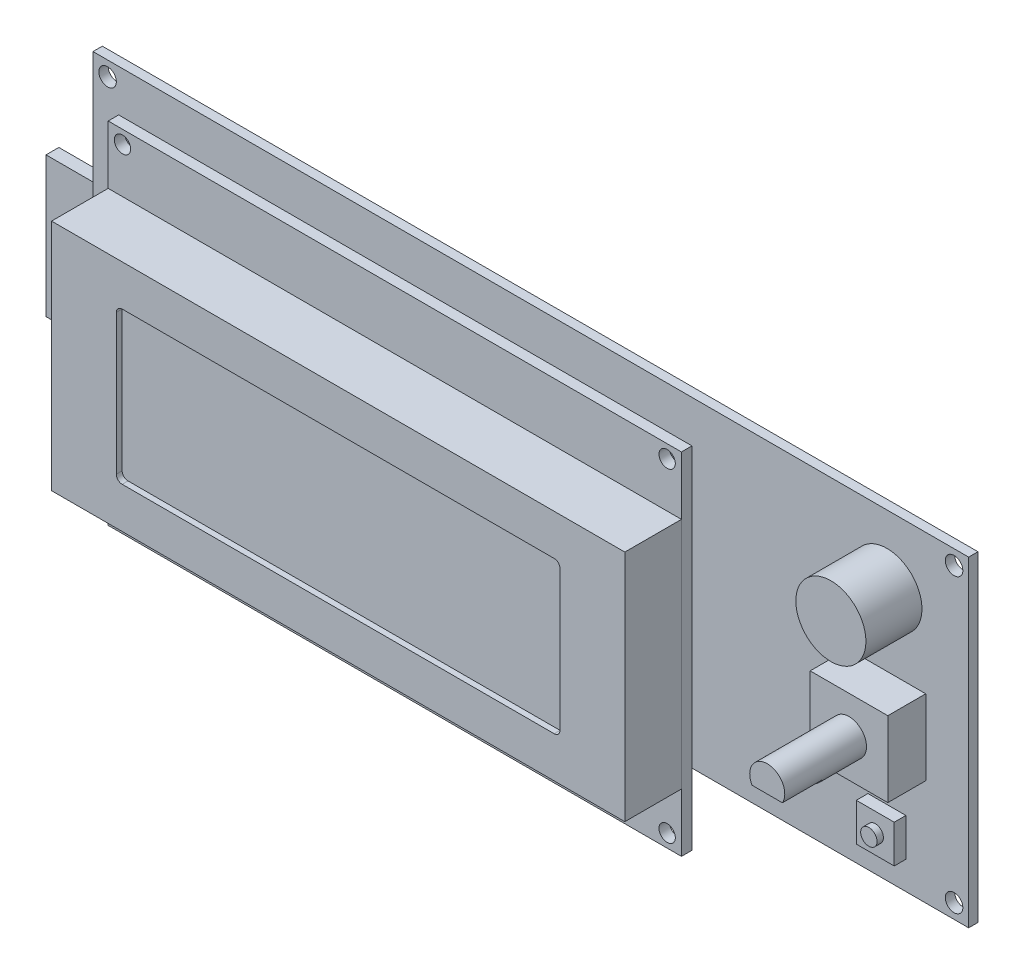
from build123d import *

# Parameters (mm, degrees)
SKETCH1_W                           = 150
SKETCH1_H                           = 55
PCB_DEPTH                           = 1.6
F_3_0_3_DIAMETER_HOLE1_D            = 3
F_3_0_3_DIAMETER_HOLE1_DEPTH        = 4
F_3_0_3_DIAMETER_HOLE1_TIP          = 0.901290929
SKETCH4_W                           = 20.3
SKETCH4_H                           = 8.8
IDC_CONN_DEPTH                      = 17.5
LPATTERN1_COUNT                     = 2
LPATTERN1_PITCH                     = 22.86
SKETCH5_W                           = 25.7
SKETCH5_H                           = 26.6
SD_SOCKET_DEPTH                     = 3.3
SKETCH6_W                           = 2.2
SKETCH6_H                           = 24
SD_CARD_DEPTH                       = 10.2
SKETCH7_R                           = 1.75
CONTRAST_POT_DEPTH                  = 2.5
EXTRUDE_2N3901_DEPTH                = 7
SKETCH9_W                           = 98.2
SKETCH9_H                           = 60
LCD_PCB_DEPTH                       = 1.8
SKETCH10_W                          = 98.2
SKETCH10_H                          = 40
LCD_HOUSING_DEPTH                   = 9.7
SKETCH11_W                          = 76
SKETCH11_H                          = 26
CUT_EXTRUDE1_DEPTH                  = 1
FILLET1_R                           = 1
F_2_8_2_8_DIAMETER_HOLE1_AT_2_COUNT = 2
F_2_8_2_8_DIAMETER_HOLE1_AT_2_PITCH = 93.3
F_2_8_2_8_DIAMETER_HOLE1_AT_3_COUNT = 2
F_2_8_2_8_DIAMETER_HOLE1_AT_3_PITCH = 108.55938467
F_2_8_2_8_DIAMETER_HOLE1_AT_4_COUNT = 2
F_2_8_2_8_DIAMETER_HOLE1_AT_4_PITCH = 55.5
SKETCH14_R                          = 6
BUZZER_DEPTH                        = 9.6
SKETCH15_W                          = 13.3
SKETCH15_H                          = 12.9
ENC_BODY_DEPTH                      = 6.5
SKETCH16_R                          = 3
ENC_SHAFT_DEPTH                     = 14
SKETCH17_W                          = 5.196152422
SKETCH17_H                          = 1.5
ENC_SHAFT_FLAT_DEPTH                = 6.8
SKETCH18_W                          = 6.5
SKETCH18_H                          = 6.5
E_STOP_SW_BODY_DEPTH                = 2
SKETCH19_R                          = 1.4
E_STOP_SW_BUTTON_DEPTH              = 1.1


with BuildPart() as part:
    # Sketch1 → PCB (new body)
    with BuildSketch(Plane.XY):
        Rectangle(SKETCH1_W, SKETCH1_H)
    extrude(amount=-PCB_DEPTH)

    # Ø3.0 (3) Diameter Hole1
    with Locations(Plane.XY):
        with Locations((-72.5, 25), (72.5, 25), (72.5, -25), (-72.5, -25)):
            Hole(F_3_0_3_DIAMETER_HOLE1_D / 2, depth=F_3_0_3_DIAMETER_HOLE1_DEPTH)
            with Locations((0, 0, -(F_3_0_3_DIAMETER_HOLE1_DEPTH + F_3_0_3_DIAMETER_HOLE1_TIP / 2))):  # 118° drill point
                Cone(0, F_3_0_3_DIAMETER_HOLE1_D / 2, F_3_0_3_DIAMETER_HOLE1_TIP, mode=Mode.SUBTRACT)

    # Sketch4 → IDC conn (add)
    with BuildSketch(Plane(origin=(0, 0, -1.6), x_dir=(-1, 0, 0), z_dir=(0, 0, -1))):
        with Locations((-4.05, 0.6)):
            Rectangle(SKETCH4_W, SKETCH4_H)
    idc_conn = extrude(amount=IDC_CONN_DEPTH)

    # LPattern1: IDC conn ×2
    with Locations(*[(-i * LPATTERN1_PITCH, 0, 0) for i in range(1, LPATTERN1_COUNT)]):
        add(idc_conn)



with BuildPart() as body_2:
    # Sketch5 → SD socket (new body)
    with BuildSketch(Plane(origin=(0, 0, -1.6), x_dir=(-1, 0, 0), z_dir=(0, 0, -1))):
        with Locations((62.15, -6)):
            Rectangle(SKETCH5_W, SKETCH5_H)
    extrude(amount=SD_SOCKET_DEPTH)


with BuildPart() as part_1:
    add(part.part)

    add(body_2.part)  # SD card merges body 2
    # Sketch6 → SD card (add)
    with BuildSketch(Plane.ZY.offset(75)):
        with Locations((-3.25, -6)):
            Rectangle(SKETCH6_W, SKETCH6_H)
    extrude(amount=SD_CARD_DEPTH)

    # Sketch7 → Contrast pot (add)
    with BuildSketch(Plane(origin=(0, 0, -1.6), x_dir=(-1, 0, 0), z_dir=(0, 0, -1))):
        with Locations((50.7, 13.1)):
            Circle(SKETCH7_R)
        Polygon((50.95, 12.85), (51.7, 12.85), (51.7, 13.35), (50.95, 13.35), (50.95, 14.1), (50.45, 14.1), (50.45, 13.35), (49.7, 13.35), (49.7, 12.85), (50.45, 12.85), (50.45, 12.1), (50.95, 12.1), align=None, mode=Mode.SUBTRACT)
    extrude(amount=CONTRAST_POT_DEPTH)

    # Sketch8 → 2N3901 (add)
    with BuildSketch(Plane(origin=(0, 0, -1.6), x_dir=(-1, 0, 0), z_dir=(0, 0, -1))):
        with BuildLine():
            Line((-3.8, 11.070683188), (-3.8, 14.729316812))
            ThreePointArc((-3.8, 14.729316812), (-7.56, 12.9), (-3.8, 11.070683188))
        make_face()
    extrude(amount=EXTRUDE_2N3901_DEPTH)

    # Sketch14 → buzzer (add)
    with BuildSketch(Plane.XY):
        with Locations(Location((61, 15.8, 0), (0, 0, 180))):
            Circle(SKETCH14_R)
    extrude(amount=BUZZER_DEPTH)

    # Sketch15 → enc body (add)
    with BuildSketch(Plane.XY):
        with Locations((61, -2.9)):
            Rectangle(SKETCH15_W, SKETCH15_H)
    extrude(amount=ENC_BODY_DEPTH)

    # Sketch16 → enc shaft (add)
    with BuildSketch(Plane.XY.offset(6.5)):
        with Locations(Location((61, -2.9, 0), (0, 0, 180))):
            Circle(SKETCH16_R)
    extrude(amount=ENC_SHAFT_DEPTH)

    # Sketch17 → enc shaft flat (cut)
    with BuildSketch(Plane.XY.offset(20.5)):
        with Locations((61, -5.15)):
            Rectangle(SKETCH17_W, SKETCH17_H)
    extrude(amount=-ENC_SHAFT_FLAT_DEPTH, mode=Mode.SUBTRACT)

    # Sketch18 → e-stop sw body (add)
    with BuildSketch(Plane.XY):
        with Locations((61, -19.45)):
            Rectangle(SKETCH18_W, SKETCH18_H)
    extrude(amount=E_STOP_SW_BODY_DEPTH)

    # Sketch19 → e-stop sw button (add)
    with BuildSketch(Plane.XY.offset(2)):
        with Locations(Location((61, -19.45, 0), (0, 0, 180))):
            Circle(SKETCH19_R)
    extrude(amount=E_STOP_SW_BUTTON_DEPTH)


with BuildPart() as body_2_2:
    # Sketch9 → LCD PCB (new body)
    with BuildSketch(Plane.XY.offset(4)):
        with Locations((-17.5, -5.7)):
            Rectangle(SKETCH9_W, SKETCH9_H)
    extrude(amount=LCD_PCB_DEPTH)

    # Sketch12 → Ø2.8 (2.8) Diameter Hole1 (revolve, cut)
    with BuildSketch(Plane(origin=(-64.15, 22.05, 5.8), x_dir=(0, -1, 0), z_dir=(1, 0, 0))):
        Polygon((0, 0), (0, 4.841204867), (1.4, 4), (1.4, 0), align=None)
    f_2_8_2_8_diameter_hole1 = revolve(axis=Axis((-64.15, 22.05, 12.15), (0, 0, -1)), mode=Mode.SUBTRACT)

    # Ø2.8 (2.8) Diameter Hole1 at 2: Ø2.8 (2.8) Diameter Hole1 ×2
    with Locations(*[(i * F_2_8_2_8_DIAMETER_HOLE1_AT_2_PITCH, 0, 0) for i in range(1, F_2_8_2_8_DIAMETER_HOLE1_AT_2_COUNT)]):
        add(f_2_8_2_8_diameter_hole1, mode=Mode.SUBTRACT)

    # Ø2.8 (2.8) Diameter Hole1 at 3: Ø2.8 (2.8) Diameter Hole1 ×2
    with Locations(*[Vector(0.8594374432328761, -0.511240922823415, 0) * (i * F_2_8_2_8_DIAMETER_HOLE1_AT_3_PITCH) for i in range(1, F_2_8_2_8_DIAMETER_HOLE1_AT_3_COUNT)]):
        add(f_2_8_2_8_diameter_hole1, mode=Mode.SUBTRACT)

    # Ø2.8 (2.8) Diameter Hole1 at 4: Ø2.8 (2.8) Diameter Hole1 ×2
    with Locations(*[(0, -i * F_2_8_2_8_DIAMETER_HOLE1_AT_4_PITCH, 0) for i in range(1, F_2_8_2_8_DIAMETER_HOLE1_AT_4_COUNT)]):
        add(f_2_8_2_8_diameter_hole1, mode=Mode.SUBTRACT)


with BuildPart() as body_3:
    # Sketch10 → LCD housing (new body)
    with BuildSketch(Plane.XY.offset(5.8)):
        with Locations((-17.5, -5.7)):
            Rectangle(SKETCH10_W, SKETCH10_H)
    extrude(amount=LCD_HOUSING_DEPTH)

    # Sketch11 → Cut-Extrude1 (cut)
    with BuildSketch(Plane.XY.offset(15.5)):
        with Locations((-17.5, -5.7)):
            Rectangle(SKETCH11_W, SKETCH11_H)
    extrude(amount=-CUT_EXTRUDE1_DEPTH, mode=Mode.SUBTRACT)

    # Fillet1
    fillet1_edges = [body_3.edges().sort_by_distance(p)[0] for p in [
        (-55.5, -18.7, 15),
        (-55.5, 7.3, 15),
        (20.5, 7.3, 15),
        (20.5, -18.7, 15),
    ]]
    fillet(fillet1_edges, radius=FILLET1_R)


solid = Compound([part_1.part, body_2_2.part, body_3.part])
